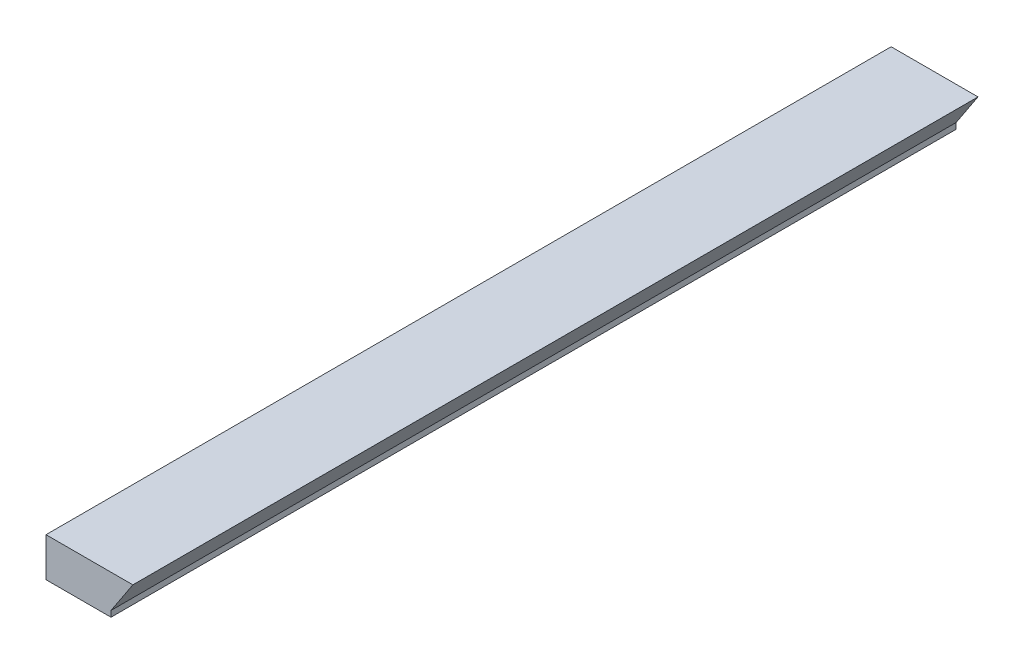
from build123d import *

# Parameters (mm, degrees)
BOSS_EXTRUDE1_DEPTH = 65


with BuildPart() as part:
    # Sketch1 → Boss-Extrude1 (new body)
    with BuildSketch(Plane.XY):
        Polygon((0, 3), (1.680458684, 3), (0, 0.453850479), (0, 0), (-5, 0), (-5, 3), align=None)
    extrude(amount=BOSS_EXTRUDE1_DEPTH)


solid = part.part
